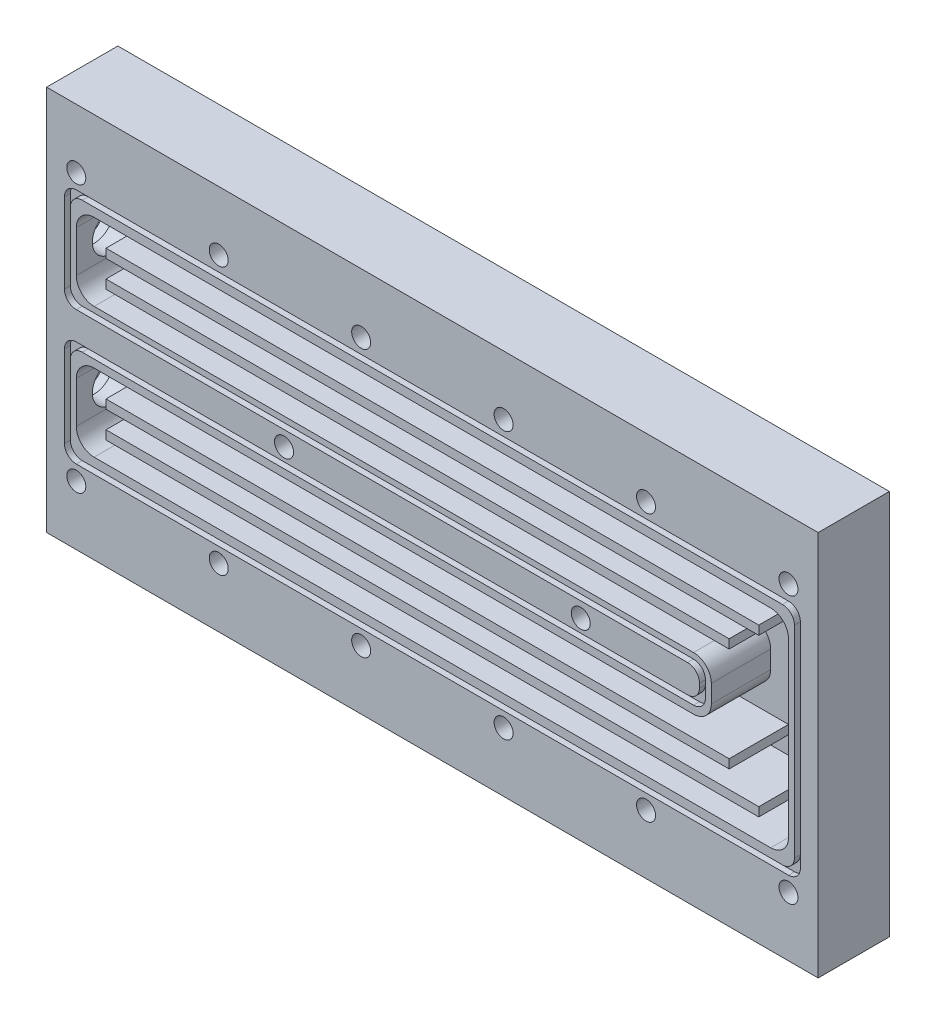
from build123d import *

# Parameters (mm, degrees)
ESQUISSE1_W             = 130
ESQUISSE1_H             = 65
BOSS_EXTRU_1_DEPTH      = 12
ESQUISSE2_R             = 1.6
ENL_V_MAT_EXTRU_1_DEPTH = 13
ENL_V_MAT_EXTRU_6_DEPTH = 10
D_GAGEMENT_M61_D        = 6.6
D_GAGEMENT_M61_DEPTH    = 6.017159957
D_GAGEMENT_M61_TIP      = 1.982840043
ESQUISSE10_R            = 4
ENL_V_MAT_EXTRU_7_DEPTH = 2
ENL_V_MAT_EXTRU_9_DEPTH = 1
ESQUISSE12_W            = 105
ESQUISSE12_H            = 1.5
ESQUISSE12_W_2          = 110
BOSS_EXTRU_2_DEPTH      = 10


with BuildPart() as part:
    # Esquisse1 → Boss.-Extru.1 (new body)
    with BuildSketch(Plane.XY):
        with Locations((65, 32.5)):
            Rectangle(ESQUISSE1_W, ESQUISSE1_H)
    extrude(amount=BOSS_EXTRU_1_DEPTH)

    # Esquisse2 → Enlèv. mat.-Extru.1 (cut, through all)
    with BuildSketch(Plane.XY.offset(12)):
        with Locations((5, 55)):
            Circle(ESQUISSE2_R)
        with Locations((29, 55)):
            Circle(ESQUISSE2_R)
        with Locations((53, 55)):
            Circle(ESQUISSE2_R)
        with Locations((77, 55)):
            Circle(ESQUISSE2_R)
        with Locations((101, 55)):
            Circle(ESQUISSE2_R)
        with Locations((125, 55)):
            Circle(ESQUISSE2_R)
        with Locations((5, 10)):
            Circle(ESQUISSE2_R)
        with Locations((29, 10)):
            Circle(ESQUISSE2_R)
        with Locations((53, 10)):
            Circle(ESQUISSE2_R)
        with Locations((77, 10)):
            Circle(ESQUISSE2_R)
        with Locations((101, 10)):
            Circle(ESQUISSE2_R)
        with Locations((125, 10)):
            Circle(ESQUISSE2_R)
        with Locations((90, 32.5)):
            Circle(ESQUISSE2_R)
        with Locations((40, 32.5)):
            Circle(ESQUISSE2_R)
    extrude(amount=-ENL_V_MAT_EXTRU_1_DEPTH, mode=Mode.SUBTRACT)

    # Esquisse6 → Enlèv. mat.-Extru.6 (cut)
    with BuildSketch(Plane.XY.offset(12)):
        with BuildLine():
            Line((8, 50), (122, 50))
            ThreePointArc((122, 50), (124.121320344, 49.121320344), (125, 47))
            Line((125, 47), (125, 18))
            ThreePointArc((125, 18), (124.121320344, 15.878679656), (122, 15))
            Line((122, 15), (8, 15))
            ThreePointArc((8, 15), (5.878679656, 15.878679656), (5, 18))
            Line((5, 18), (5, 25))
            ThreePointArc((5, 25), (5.878679656, 27.121320344), (8, 28))
            Line((8, 28), (109, 28))
            ThreePointArc((109, 28), (111.121320344, 28.878679656), (112, 31))
            Line((112, 31), (112, 34))
            ThreePointArc((112, 34), (111.121320344, 36.121320344), (109, 37))
            Line((109, 37), (8, 37))
            ThreePointArc((8, 37), (5.878679656, 37.878679656), (5, 40))
            Line((5, 40), (5, 47))
            ThreePointArc((5, 47), (5.878679656, 49.121320344), (8, 50))
        make_face()
    extrude(amount=-ENL_V_MAT_EXTRU_6_DEPTH, mode=Mode.SUBTRACT)

    # Dégagement M61
    with Locations(Plane.ZY):
        with Locations((6, 43.5), (6, 21.5)):
            Hole(D_GAGEMENT_M61_D / 2, depth=D_GAGEMENT_M61_DEPTH)
            with Locations((0, 0, -(D_GAGEMENT_M61_DEPTH + D_GAGEMENT_M61_TIP / 2))):  # 118° drill point
                Cone(0, D_GAGEMENT_M61_D / 2, D_GAGEMENT_M61_TIP, mode=Mode.SUBTRACT)

    # Esquisse10 → Enlèv. mat.-Extru.7 (cut)
    with BuildSketch(Plane.ZY):
        with Locations((6, 21.5)):
            Circle(ESQUISSE10_R)
        with Locations((6, 43.5)):
            Circle(ESQUISSE10_R)
    extrude(amount=-ENL_V_MAT_EXTRU_7_DEPTH, mode=Mode.SUBTRACT)

    # Esquisse11 → Enlèv. mat.-Extru.9 (cut)
    with BuildSketch(Plane.XY.offset(12)):
        with BuildLine():
            Line((125, 12.5), (5, 12.5))
            ThreePointArc((5, 12.5), (3.585786438, 13.085786438), (3, 14.5))
            Line((3, 14.5), (3, 28.315802411))
            ThreePointArc((3, 28.315802411), (3.585786438, 29.730015973), (5, 30.315802411))
            Line((5, 30.315802411), (108, 30.315802411))
            ThreePointArc((108, 30.315802411), (109.414213562, 30.901588849), (110, 32.315802411))
            Line((110, 32.315802411), (110, 33.034217912))
            ThreePointArc((110, 33.034217912), (109.414213562, 34.448431474), (108, 35.034217912))
            Line((108, 35.034217912), (5, 35.034217912))
            ThreePointArc((5, 35.034217912), (3.585786438, 35.620004349), (3, 37.034217912))
            Line((3, 37.034217912), (3, 50.5))
            ThreePointArc((3, 50.5), (3.585786438, 51.914213562), (5, 52.5))
            Line((5, 52.5), (125, 52.5))
            ThreePointArc((125, 52.5), (126.414213562, 51.914213562), (127, 50.5))
            Line((127, 50.5), (127, 14.5))
            ThreePointArc((127, 14.5), (126.414213562, 13.085786438), (125, 12.5))
        make_face()
        with BuildLine():
            Line((6, 51.5), (124, 51.5))
            ThreePointArc((124, 51.5), (125.414213562, 50.914213562), (126, 49.5))
            Line((126, 49.5), (126, 15.5))
            ThreePointArc((126, 15.5), (125.414213562, 14.085786438), (124, 13.5))
            Line((124, 13.5), (6, 13.5))
            ThreePointArc((6, 13.5), (4.585786438, 14.085786438), (4, 15.5))
            Line((4, 15.5), (4, 27.315802411))
            ThreePointArc((4, 27.315802411), (4.585786438, 28.730015973), (6, 29.315802411))
            Line((6, 29.315802411), (109, 29.315802411))
            ThreePointArc((109, 29.315802411), (110.414213562, 29.901588849), (111, 31.315802411))
            Line((111, 31.315802411), (111, 34.034217912))
            ThreePointArc((111, 34.034217912), (110.414213562, 35.448431474), (109, 36.034217912))
            Line((109, 36.034217912), (6, 36.034217912))
            ThreePointArc((6, 36.034217912), (4.585786438, 36.620004349), (4, 38.034217912))
            Line((4, 38.034217912), (4, 49.5))
            ThreePointArc((4, 49.5), (4.585786438, 50.914213562), (6, 51.5))
        make_face(mode=Mode.SUBTRACT)
    extrude(amount=-ENL_V_MAT_EXTRU_9_DEPTH, mode=Mode.SUBTRACT)

    # Esquisse12 → Boss.-Extru.2 (add)
    with BuildSketch(Plane.XY.offset(2)):
        with Locations((62.5, 41.25)):
            Rectangle(ESQUISSE12_W, ESQUISSE12_H)
        with Locations((65, 45.75)):
            Rectangle(ESQUISSE12_W_2, ESQUISSE12_H)
        with Locations((65, 19.25)):
            Rectangle(ESQUISSE12_W_2, ESQUISSE12_H)
        with Locations((62.5, 23.75)):
            Rectangle(ESQUISSE12_W, ESQUISSE12_H)
    extrude(amount=BOSS_EXTRU_2_DEPTH)


solid = part.part
